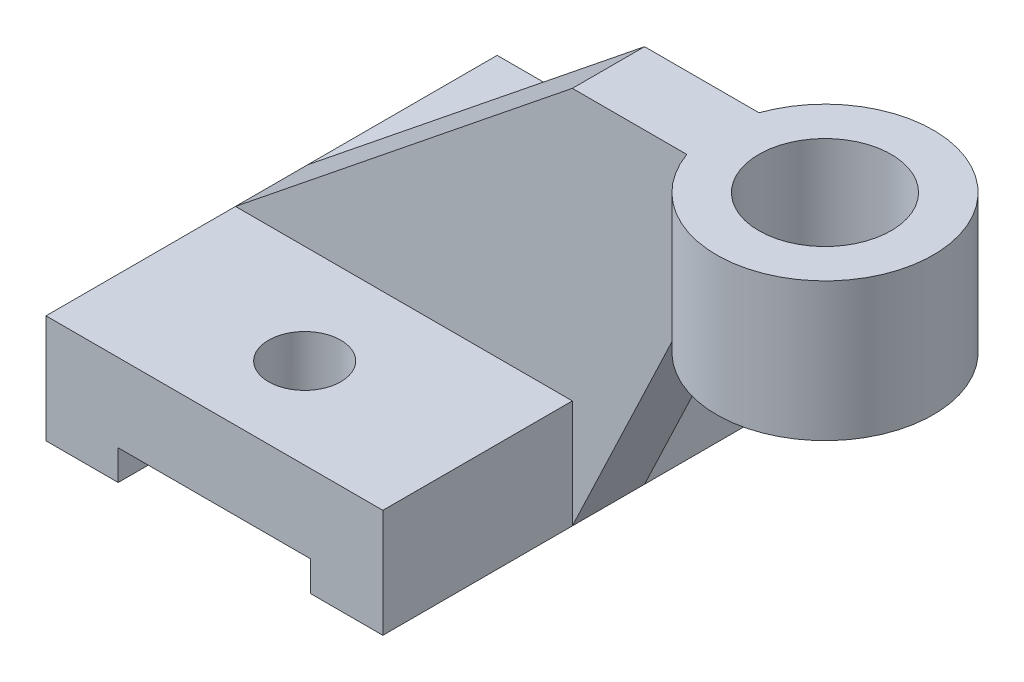
from build123d import *

# Parameters (mm, degrees)
IZIM1_W                     = 56
IZIM1_H                     = 75
Y_KSEKLIK_EKSTR_ZYON1_DEPTH = 18
IZIM3_R                     = 6
KES_EKSTR_ZYON1_DEPTH       = 96.315266353
IZIM4_W                     = 32
IZIM4_H                     = 5
KES_EKSTR_ZYON2_DEPTH       = 96.315266353
Y_KSEKLIK_EKSTR_ZYON2_DEPTH = 6
IZIM7_R                     = 11
Y_KSEKLIK_EKSTR_ZYON3_DEPTH = 23
FEDER1_REACH                = 134.194
IZIM8_WALL_W                = 310.68379038
IZIM8_WALL_H                = 12


with BuildPart() as part:
    # Çizim1 → Yükseklik-Ekstrüzyon1 (new body)
    with BuildSketch(Plane(origin=(0, 0, 0), x_dir=(1, 0, 0), z_dir=(0, 1, 0))):
        with Locations((28, -37.5)):
            Rectangle(IZIM1_W, IZIM1_H)
    extrude(amount=Y_KSEKLIK_EKSTR_ZYON1_DEPTH)

    # Çizim3 → Kes-Ekstrüzyon1 (cut, through all)
    with BuildSketch(Plane(origin=(0, 18, 0), x_dir=(1, 0, 0), z_dir=(0, 1, 0))):
        with Locations(Location((28, -15, 0), (0, 0, 270))):
            Circle(IZIM3_R)
        with Locations(Location((28, -60, 0), (0, 0, 270))):
            Circle(IZIM3_R)
    extrude(amount=-KES_EKSTR_ZYON1_DEPTH, mode=Mode.SUBTRACT)

    # Çizim4 → Kes-Ekstrüzyon2 (cut, through all)
    with BuildSketch(Plane.XY.offset(75)):
        with Locations((28, 2.5)):
            Rectangle(IZIM4_W, IZIM4_H)
    extrude(amount=-KES_EKSTR_ZYON2_DEPTH, mode=Mode.SUBTRACT)

    # Çizim5 → Yükseklik-Ekstrüzyon2 (add, symmetric)
    with BuildSketch(Plane.XY.offset(37.5)):
        Polygon((0, 18), (56, 18), (56, 63), align=None)
    extrude(amount=Y_KSEKLIK_EKSTR_ZYON2_DEPTH, both=True)

    # Çizim7 → Yükseklik-Ekstrüzyon3 (add)
    with BuildSketch(Plane(origin=(0, 63, 0), x_dir=(1, 0, 0), z_dir=(0, 1, 0))):
        with BuildLine():
            Line((56, -31.5), (75.029437252, -31.5))
            ThreePointArc((75.029437252, -31.5), (110, -37.5), (75.029437252, -43.5))
            Line((75.029437252, -43.5), (56, -43.5))
            Line((56, -43.5), (56, -37.5))
            Line((56, -37.5), (56, -31.5))
        make_face()
        with Locations(Location((92, -37.5, 0), (0, 0, 270))):
            Circle(IZIM7_R, mode=Mode.SUBTRACT)
    extrude(amount=-Y_KSEKLIK_EKSTR_ZYON3_DEPTH)

    # Çizim8 wall → Feder1 (add, up to next)
    with BuildSketch(Plane(origin=(65.514718626, 20, 37.5), x_dir=(0.42959895901, 0.903019786283, 0), z_dir=(-0.903019786283, 0.42959895901, 0)), mode=Mode.PRIVATE) as feder1_sk1:
        Rectangle(IZIM8_WALL_W, IZIM8_WALL_H)
    feder1_tool1 = extrude(feder1_sk1.sketch, amount=FEDER1_REACH, mode=Mode.PRIVATE) - part.part
    add(feder1_tool1.solids().sort_by_distance((65.514718626, 20, 37.5))[0])


solid = part.part
